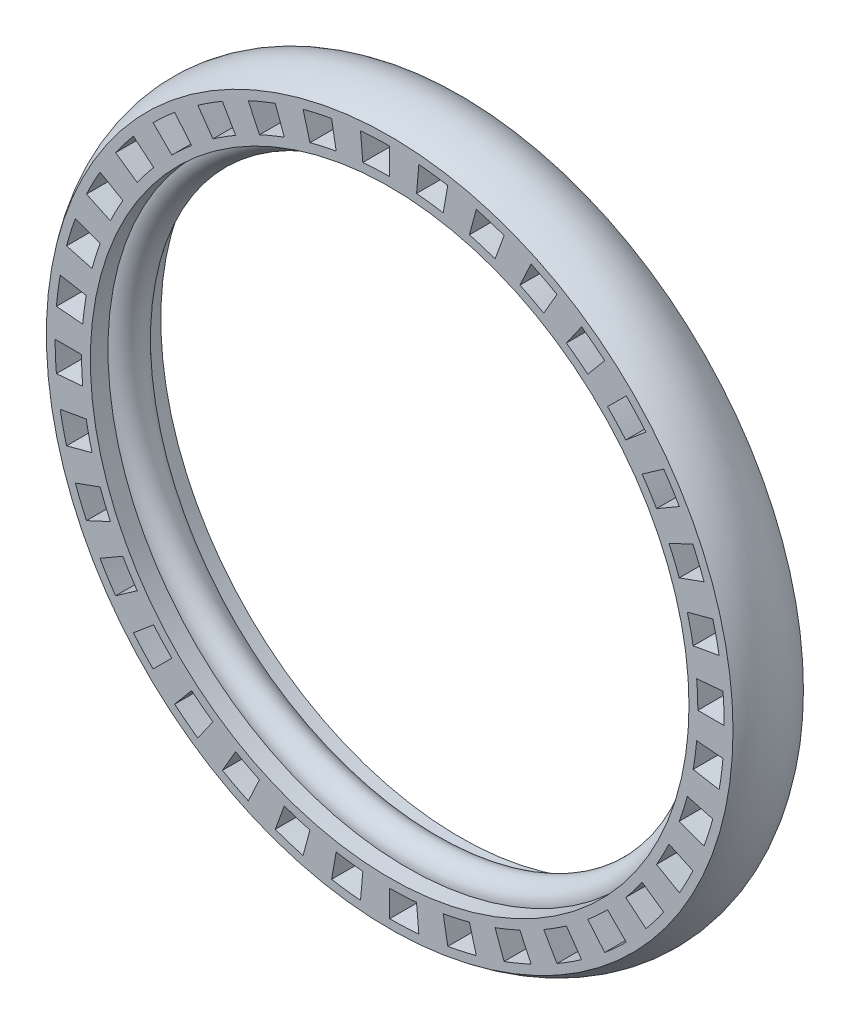
from build123d import *

# Parameters (mm, degrees)
CUT_EXTRUDE_1_DEPTH = 8


with BuildPart() as part:
    # 草图1 → 旋转1 (revolve)
    with BuildSketch(Plane(origin=(0, 0, 0), x_dir=(1, 0, 0), z_dir=(0, 1, 0))):
        with BuildLine():
            Line((-34, 2), (-34, 4))
            Line((-34, 4), (-39, 4))
            ThreePointArc((-39, 4), (-40.403124237, 0), (-39, -4))
            Line((-39, -4), (-34, -4))
            Line((-34, -4), (-34, -2))
            ThreePointArc((-34, -2), (-32, 0), (-34, 2))
        make_face()
    revolve(axis=Axis((0, 0, 0), (0, 0, -1)))

    # 草图2 → 切除-拉伸1 (cut)
    with BuildSketch(Plane(origin=(0, 0, -4), x_dir=(-1, 0, 0), z_dir=(0, 0, -1))):
        with BuildLine():
            Line((0, 35), (0, 38))
            ThreePointArc((0, 38), (1.65753672, 37.96383242), (3.311918224, 37.855398527))
            Line((3.311918224, 37.855398527), (3.050450996, 34.866814433))
            ThreePointArc((3.050450996, 34.866814433), (1.526678558, 34.966687755), (0, 35))
        make_face()
        with BuildLine():
            Line((6.077686218, 34.468271355), (6.598630751, 37.422694614))
            ThreePointArc((6.598630751, 37.422694614), (8.22470533, 37.099248271), (9.835123714, 36.705181399))
            Line((9.835123714, 36.705181399), (9.058666579, 33.80740392))
            ThreePointArc((9.058666579, 33.80740392), (7.575386488, 34.170360249), (6.077686218, 34.468271355))
        make_face()
        with BuildLine():
            Line((11.970705016, 32.889241728), (12.996765446, 35.70831959))
            ThreePointArc((12.996765446, 35.70831959), (14.54197043, 35.107422235), (16.059493946, 34.439695907))
            Line((16.059493946, 34.439695907), (14.791639161, 31.720772546))
            ThreePointArc((14.791639161, 31.720772546), (13.393920133, 32.335783638), (11.970705016, 32.889241728))
        make_face()
        with BuildLine():
            Line((17.5, 30.310889132), (19, 32.908965344))
            ThreePointArc((19, 32.908965344), (20.417385117, 32.048874941), (21.795904581, 31.127777683))
            Line((21.795904581, 31.127777683), (20.075175272, 28.67032155))
            ThreePointArc((20.075175272, 28.67032155), (18.805486292, 29.518700603), (17.5, 30.310889132))
        make_face()
        with BuildLine():
            Line((22.497566339, 26.811555509), (24.425929168, 29.109688839))
            ThreePointArc((24.425929168, 29.109688839), (25.672427889, 28.016538799), (26.870057685, 26.870057685))
            Line((26.870057685, 26.870057685), (24.748737342, 24.748737342))
            ThreePointArc((24.748737342, 24.748737342), (23.645657267, 25.804706788), (22.497566339, 26.811555509))
        make_face()
        with BuildLine():
            Line((26.811555509, 22.497566339), (29.109688839, 24.425929168))
            ThreePointArc((29.109688839, 24.425929168), (30.147426931, 23.132934302), (31.127777683, 21.795904581))
            Line((31.127777683, 21.795904581), (28.67032155, 20.075175272))
            ThreePointArc((28.67032155, 20.075175272), (27.76736691, 21.306650015), (26.811555509, 22.497566339))
        make_face()
        with BuildLine():
            Line((30.310889132, 17.5), (32.908965344, 19))
            ThreePointArc((32.908965344, 19), (33.706411661, 17.546447303), (34.439695907, 16.059493946))
            Line((34.439695907, 16.059493946), (31.720772546, 14.791639161))
            ThreePointArc((31.720772546, 14.791639161), (31.045379161, 16.161201463), (30.310889132, 17.5))
        make_face()
        with BuildLine():
            Line((32.889241728, 11.970705016), (35.70831959, 12.996765446))
            ThreePointArc((35.70831959, 12.996765446), (36.241244128, 11.426820381), (36.705181399, 9.835123714))
            Line((36.705181399, 9.835123714), (33.80740392, 9.058666579))
            ThreePointArc((33.80740392, 9.058666579), (33.380093276, 10.524702983), (32.889241728, 11.970705016))
        make_face()
        with BuildLine():
            Line((34.468271355, 6.077686218), (37.422694614, 6.598630751))
            ThreePointArc((37.422694614, 6.598630751), (37.674904732, 4.959995304), (37.855398527, 3.311918224))
            Line((37.855398527, 3.311918224), (34.866814433, 3.050450996))
            ThreePointArc((34.866814433, 3.050450996), (34.700570148, 4.568416728), (34.468271355, 6.077686218))
        make_face()
        with BuildLine():
            Line((35, 0), (38, 0))
            ThreePointArc((38, 0), (37.96383242, -1.65753672), (37.855398527, -3.311918224))
            Line((37.855398527, -3.311918224), (34.866814433, -3.050450996))
            ThreePointArc((34.866814433, -3.050450996), (34.966687755, -1.526678558), (35, 0))
        make_face()
        with BuildLine():
            Line((34.468271355, -6.077686218), (37.422694614, -6.598630751))
            ThreePointArc((37.422694614, -6.598630751), (37.099248271, -8.22470533), (36.705181399, -9.835123714))
            Line((36.705181399, -9.835123714), (33.80740392, -9.058666579))
            ThreePointArc((33.80740392, -9.058666579), (34.170360249, -7.575386488), (34.468271355, -6.077686218))
        make_face()
        with BuildLine():
            Line((32.889241728, -11.970705016), (35.70831959, -12.996765446))
            ThreePointArc((35.70831959, -12.996765446), (35.107422235, -14.54197043), (34.439695907, -16.059493946))
            Line((34.439695907, -16.059493946), (31.720772546, -14.791639161))
            ThreePointArc((31.720772546, -14.791639161), (32.335783638, -13.393920133), (32.889241728, -11.970705016))
        make_face()
        with BuildLine():
            Line((30.310889132, -17.5), (32.908965344, -19))
            ThreePointArc((32.908965344, -19), (32.048874941, -20.417385117), (31.127777683, -21.795904581))
            Line((31.127777683, -21.795904581), (28.67032155, -20.075175272))
            ThreePointArc((28.67032155, -20.075175272), (29.518700603, -18.805486292), (30.310889132, -17.5))
        make_face()
        with BuildLine():
            Line((26.811555509, -22.497566339), (29.109688839, -24.425929168))
            ThreePointArc((29.109688839, -24.425929168), (28.016538799, -25.672427889), (26.870057685, -26.870057685))
            Line((26.870057685, -26.870057685), (24.748737342, -24.748737342))
            ThreePointArc((24.748737342, -24.748737342), (25.804706788, -23.645657267), (26.811555509, -22.497566339))
        make_face()
        with BuildLine():
            Line((22.497566339, -26.811555509), (24.425929168, -29.109688839))
            ThreePointArc((24.425929168, -29.109688839), (23.132934302, -30.147426931), (21.795904581, -31.127777683))
            Line((21.795904581, -31.127777683), (20.075175272, -28.67032155))
            ThreePointArc((20.075175272, -28.67032155), (21.306650015, -27.76736691), (22.497566339, -26.811555509))
        make_face()
        with BuildLine():
            Line((17.5, -30.310889132), (19, -32.908965344))
            ThreePointArc((19, -32.908965344), (17.546447303, -33.706411661), (16.059493946, -34.439695907))
            Line((16.059493946, -34.439695907), (14.791639161, -31.720772546))
            ThreePointArc((14.791639161, -31.720772546), (16.161201463, -31.045379161), (17.5, -30.310889132))
        make_face()
        with BuildLine():
            Line((11.970705016, -32.889241728), (12.996765446, -35.70831959))
            ThreePointArc((12.996765446, -35.70831959), (11.426820381, -36.241244128), (9.835123714, -36.705181399))
            Line((9.835123714, -36.705181399), (9.058666579, -33.80740392))
            ThreePointArc((9.058666579, -33.80740392), (10.524702983, -33.380093276), (11.970705016, -32.889241728))
        make_face()
        with BuildLine():
            Line((6.077686218, -34.468271355), (6.598630751, -37.422694614))
            ThreePointArc((6.598630751, -37.422694614), (4.959995304, -37.674904732), (3.311918224, -37.855398527))
            Line((3.311918224, -37.855398527), (3.050450996, -34.866814433))
            ThreePointArc((3.050450996, -34.866814433), (4.568416728, -34.700570148), (6.077686218, -34.468271355))
        make_face()
        with BuildLine():
            Line((0, -35), (0, -38))
            ThreePointArc((0, -38), (-1.65753672, -37.96383242), (-3.311918224, -37.855398527))
            Line((-3.311918224, -37.855398527), (-3.050450996, -34.866814433))
            ThreePointArc((-3.050450996, -34.866814433), (-1.526678558, -34.966687755), (0, -35))
        make_face()
        with BuildLine():
            Line((-6.077686218, -34.468271355), (-6.598630751, -37.422694614))
            ThreePointArc((-6.598630751, -37.422694614), (-8.22470533, -37.099248271), (-9.835123714, -36.705181399))
            Line((-9.835123714, -36.705181399), (-9.058666579, -33.80740392))
            ThreePointArc((-9.058666579, -33.80740392), (-7.575386488, -34.170360249), (-6.077686218, -34.468271355))
        make_face()
        with BuildLine():
            Line((-11.970705016, -32.889241728), (-12.996765446, -35.70831959))
            ThreePointArc((-12.996765446, -35.70831959), (-14.54197043, -35.107422235), (-16.059493946, -34.439695907))
            Line((-16.059493946, -34.439695907), (-14.791639161, -31.720772546))
            ThreePointArc((-14.791639161, -31.720772546), (-13.393920133, -32.335783638), (-11.970705016, -32.889241728))
        make_face()
        with BuildLine():
            Line((-17.5, -30.310889132), (-19, -32.908965344))
            ThreePointArc((-19, -32.908965344), (-20.417385117, -32.048874941), (-21.795904581, -31.127777683))
            Line((-21.795904581, -31.127777683), (-20.075175272, -28.67032155))
            ThreePointArc((-20.075175272, -28.67032155), (-18.805486292, -29.518700603), (-17.5, -30.310889132))
        make_face()
        with BuildLine():
            Line((-22.497566339, -26.811555509), (-24.425929168, -29.109688839))
            ThreePointArc((-24.425929168, -29.109688839), (-25.672427889, -28.016538799), (-26.870057685, -26.870057685))
            Line((-26.870057685, -26.870057685), (-24.748737342, -24.748737342))
            ThreePointArc((-24.748737342, -24.748737342), (-23.645657267, -25.804706788), (-22.497566339, -26.811555509))
        make_face()
        with BuildLine():
            Line((-26.811555509, -22.497566339), (-29.109688839, -24.425929168))
            ThreePointArc((-29.109688839, -24.425929168), (-30.147426931, -23.132934302), (-31.127777683, -21.795904581))
            Line((-31.127777683, -21.795904581), (-28.67032155, -20.075175272))
            ThreePointArc((-28.67032155, -20.075175272), (-27.76736691, -21.306650015), (-26.811555509, -22.497566339))
        make_face()
        with BuildLine():
            Line((-30.310889132, -17.5), (-32.908965344, -19))
            ThreePointArc((-32.908965344, -19), (-33.706411661, -17.546447303), (-34.439695907, -16.059493946))
            Line((-34.439695907, -16.059493946), (-31.720772546, -14.791639161))
            ThreePointArc((-31.720772546, -14.791639161), (-31.045379161, -16.161201463), (-30.310889132, -17.5))
        make_face()
        with BuildLine():
            Line((-32.889241728, -11.970705016), (-35.70831959, -12.996765446))
            ThreePointArc((-35.70831959, -12.996765446), (-36.241244128, -11.426820381), (-36.705181399, -9.835123714))
            Line((-36.705181399, -9.835123714), (-33.80740392, -9.058666579))
            ThreePointArc((-33.80740392, -9.058666579), (-33.380093276, -10.524702983), (-32.889241728, -11.970705016))
        make_face()
        with BuildLine():
            Line((-34.468271355, -6.077686218), (-37.422694614, -6.598630751))
            ThreePointArc((-37.422694614, -6.598630751), (-37.674904732, -4.959995304), (-37.855398527, -3.311918224))
            Line((-37.855398527, -3.311918224), (-34.866814433, -3.050450996))
            ThreePointArc((-34.866814433, -3.050450996), (-34.700570148, -4.568416728), (-34.468271355, -6.077686218))
        make_face()
        with BuildLine():
            Line((-35, 0), (-38, 0))
            ThreePointArc((-38, 0), (-37.96383242, 1.65753672), (-37.855398527, 3.311918224))
            Line((-37.855398527, 3.311918224), (-34.866814433, 3.050450996))
            ThreePointArc((-34.866814433, 3.050450996), (-34.966687755, 1.526678558), (-35, 0))
        make_face()
        with BuildLine():
            Line((-34.468271355, 6.077686218), (-37.422694614, 6.598630751))
            ThreePointArc((-37.422694614, 6.598630751), (-37.099248271, 8.22470533), (-36.705181399, 9.835123714))
            Line((-36.705181399, 9.835123714), (-33.80740392, 9.058666579))
            ThreePointArc((-33.80740392, 9.058666579), (-34.170360249, 7.575386488), (-34.468271355, 6.077686218))
        make_face()
        with BuildLine():
            Line((-32.889241728, 11.970705016), (-35.70831959, 12.996765446))
            ThreePointArc((-35.70831959, 12.996765446), (-35.107422235, 14.54197043), (-34.439695907, 16.059493946))
            Line((-34.439695907, 16.059493946), (-31.720772546, 14.791639161))
            ThreePointArc((-31.720772546, 14.791639161), (-32.335783638, 13.393920133), (-32.889241728, 11.970705016))
        make_face()
        with BuildLine():
            Line((-30.310889132, 17.5), (-32.908965344, 19))
            ThreePointArc((-32.908965344, 19), (-32.048874941, 20.417385117), (-31.127777683, 21.795904581))
            Line((-31.127777683, 21.795904581), (-28.67032155, 20.075175272))
            ThreePointArc((-28.67032155, 20.075175272), (-29.518700603, 18.805486292), (-30.310889132, 17.5))
        make_face()
        with BuildLine():
            Line((-26.811555509, 22.497566339), (-29.109688839, 24.425929168))
            ThreePointArc((-29.109688839, 24.425929168), (-28.016538799, 25.672427889), (-26.870057685, 26.870057685))
            Line((-26.870057685, 26.870057685), (-24.748737342, 24.748737342))
            ThreePointArc((-24.748737342, 24.748737342), (-25.804706788, 23.645657267), (-26.811555509, 22.497566339))
        make_face()
        with BuildLine():
            Line((-22.497566339, 26.811555509), (-24.425929168, 29.109688839))
            ThreePointArc((-24.425929168, 29.109688839), (-23.132934302, 30.147426931), (-21.795904581, 31.127777683))
            Line((-21.795904581, 31.127777683), (-20.075175272, 28.67032155))
            ThreePointArc((-20.075175272, 28.67032155), (-21.306650015, 27.76736691), (-22.497566339, 26.811555509))
        make_face()
        with BuildLine():
            Line((-17.5, 30.310889132), (-19, 32.908965344))
            ThreePointArc((-19, 32.908965344), (-17.546447303, 33.706411661), (-16.059493946, 34.439695907))
            Line((-16.059493946, 34.439695907), (-14.791639161, 31.720772546))
            ThreePointArc((-14.791639161, 31.720772546), (-16.161201463, 31.045379161), (-17.5, 30.310889132))
        make_face()
        with BuildLine():
            Line((-11.970705016, 32.889241728), (-12.996765446, 35.70831959))
            ThreePointArc((-12.996765446, 35.70831959), (-11.426820381, 36.241244128), (-9.835123714, 36.705181399))
            Line((-9.835123714, 36.705181399), (-9.058666579, 33.80740392))
            ThreePointArc((-9.058666579, 33.80740392), (-10.524702983, 33.380093276), (-11.970705016, 32.889241728))
        make_face()
        with BuildLine():
            Line((-6.077686218, 34.468271355), (-6.598630751, 37.422694614))
            ThreePointArc((-6.598630751, 37.422694614), (-4.959995304, 37.674904732), (-3.311918224, 37.855398527))
            Line((-3.311918224, 37.855398527), (-3.050450996, 34.866814433))
            ThreePointArc((-3.050450996, 34.866814433), (-4.568416728, 34.700570148), (-6.077686218, 34.468271355))
        make_face()
    extrude(amount=-CUT_EXTRUDE_1_DEPTH, mode=Mode.SUBTRACT)


solid = part.part
